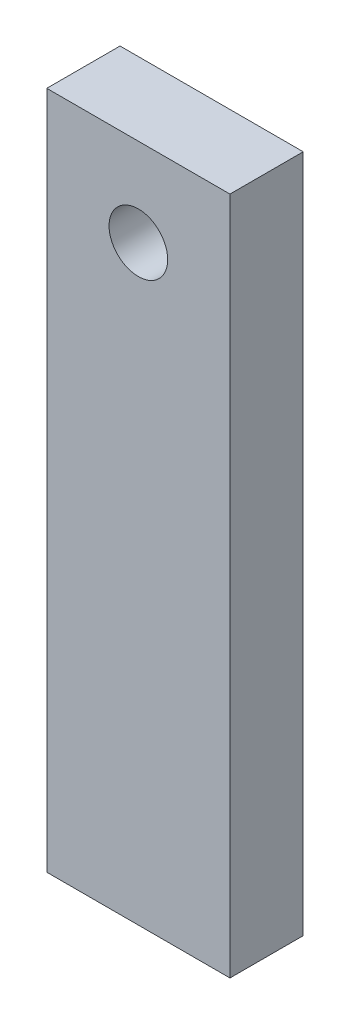
from build123d import *

# Parameters (mm, degrees)
SKETCH1_W           = 25
SKETCH1_H           = 92.6586
SKETCH1_R           = 4
BOSS_EXTRUDE1_DEPTH = 10


with BuildPart() as part:
    # Sketch1 → Boss-Extrude1 (new body)
    with BuildSketch(Plane.XY):
        Rectangle(SKETCH1_W, SKETCH1_H)
        with Locations((0, 34.3293)):
            Circle(SKETCH1_R, mode=Mode.SUBTRACT)
    extrude(amount=BOSS_EXTRUDE1_DEPTH)


solid = part.part
